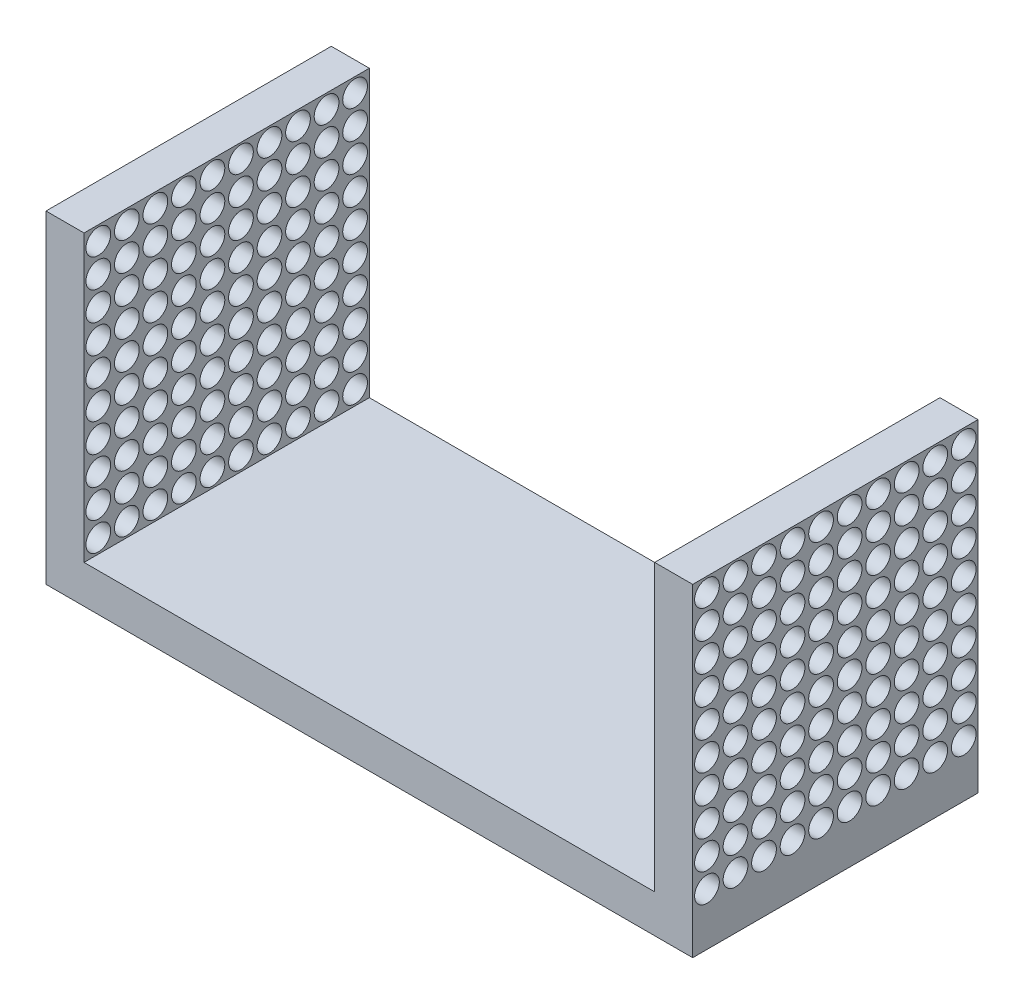
from build123d import *

# Parameters (mm, degrees)
SKETCH1_W                = 34
SKETCH1_H                = 17
BOSS_EXTRUDE1_DEPTH      = 7.5
BOSS_EXTRUDE1_DEPTH_BACK = 7.5
SKETCH2_W                = 30
SKETCH2_H                = 15
CUT_EXTRUDE1_DEPTH       = 15
SKETCH3_R                = 0.65
CUT_EXTRUDE2_DEPTH       = 34
LPATTERN1_COUNT          = 10
LPATTERN1_PITCH          = 1.5
LPATTERN1_COUNT_DIR2     = 10
LPATTERN1_PITCH_DIR2     = 1.5


with BuildPart() as part:
    # Sketch1 → Boss-Extrude1 (new body, two sides)
    with BuildSketch(Plane.XY) as boss_extrude1_sk:
        Rectangle(SKETCH1_W, SKETCH1_H)
    extrude(amount=BOSS_EXTRUDE1_DEPTH)
    extrude(boss_extrude1_sk.sketch, amount=-BOSS_EXTRUDE1_DEPTH_BACK)

    # Sketch2 → Cut-Extrude1 (cut)
    with BuildSketch(Plane.XY.offset(7.5)):
        with Locations((0, 1)):
            Rectangle(SKETCH2_W, SKETCH2_H)
    extrude(amount=-CUT_EXTRUDE1_DEPTH, mode=Mode.SUBTRACT)

    # Sketch3 → Cut-Extrude2 (cut)
    with BuildSketch(Plane(origin=(17, 0, 0), x_dir=(0, 0, -1), z_dir=(1, 0, 0))):
        with Locations((-6.75, 7.75)):
            Circle(SKETCH3_R)
    cut_extrude2 = extrude(amount=-CUT_EXTRUDE2_DEPTH, mode=Mode.SUBTRACT)

    # LPattern1: Cut-Extrude2 10 × 10
    with Locations(*[(0, -j * LPATTERN1_PITCH_DIR2, -i * LPATTERN1_PITCH) for i in range(LPATTERN1_COUNT) for j in range(LPATTERN1_COUNT_DIR2) if (i, j) != (0, 0)]):
        add(cut_extrude2, mode=Mode.SUBTRACT)


solid = part.part
